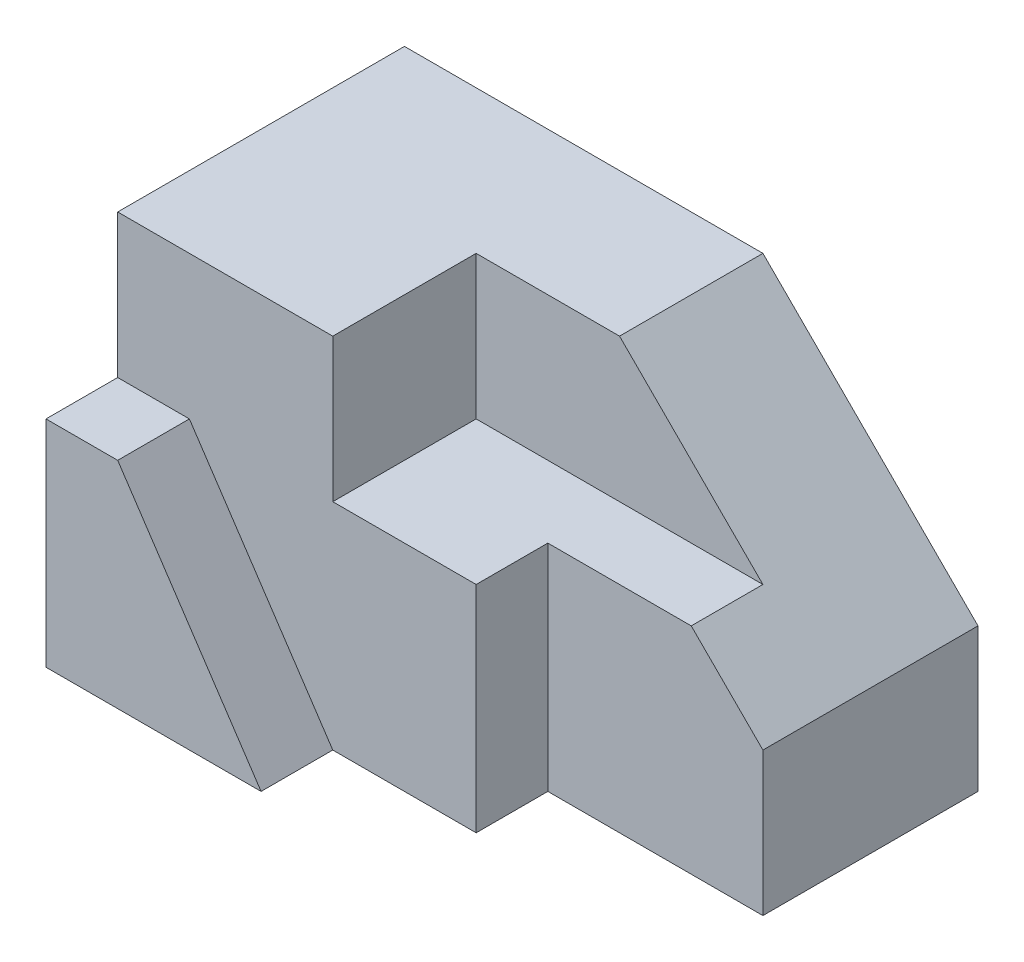
from build123d import *

# Parameters (mm, degrees)
SKETCH1_W           = 80
SKETCH1_H           = 50
BOSS_EXTRUDE1_DEPTH = 50
CUT_EXTRUDE1_DEPTH  = 10
CUT_EXTRUDE2_DEPTH  = 56
SKETCH4_W           = 30
SKETCH4_H           = 10
CUT_EXTRUDE3_DEPTH  = 56
SKETCH5_W           = 82.14120513
SKETCH5_H           = 20
CUT_EXTRUDE4_DEPTH  = 20


with BuildPart() as part:
    # Sketch1 → Boss-Extrude1 (new body)
    with BuildSketch(Plane.XY):
        with Locations((40, 25)):
            Rectangle(SKETCH1_W, SKETCH1_H)
    extrude(amount=-BOSS_EXTRUDE1_DEPTH)

    # Sketch2 → Cut-Extrude1 (cut)
    with BuildSketch(Plane.XY):
        Polygon((0, 30), (0, 50), (80, 50), (80, 0), (30, 0), (10, 30), align=None)
    extrude(amount=-CUT_EXTRUDE1_DEPTH, mode=Mode.SUBTRACT)

    # Sketch3 → Cut-Extrude2 (cut)
    with BuildSketch(Plane.XY.offset(-10)):
        Polygon((50, 50), (80, 20), (80, 50), align=None)
    extrude(amount=-CUT_EXTRUDE2_DEPTH, mode=Mode.SUBTRACT)

    # Sketch4 → Cut-Extrude3 (cut)
    with BuildSketch(Plane.XZ):
        with Locations((65, -15)):
            Rectangle(SKETCH4_W, SKETCH4_H)
    extrude(amount=-CUT_EXTRUDE3_DEPTH, mode=Mode.SUBTRACT)

    # Sketch5 → Cut-Extrude4 (cut)
    with BuildSketch(Plane(origin=(0, 50, 0), x_dir=(1, 0, 0), z_dir=(0, 1, 0))):
        with Locations((71.070602565, 20)):
            Rectangle(SKETCH5_W, SKETCH5_H)
    extrude(amount=-CUT_EXTRUDE4_DEPTH, mode=Mode.SUBTRACT)


solid = part.part
